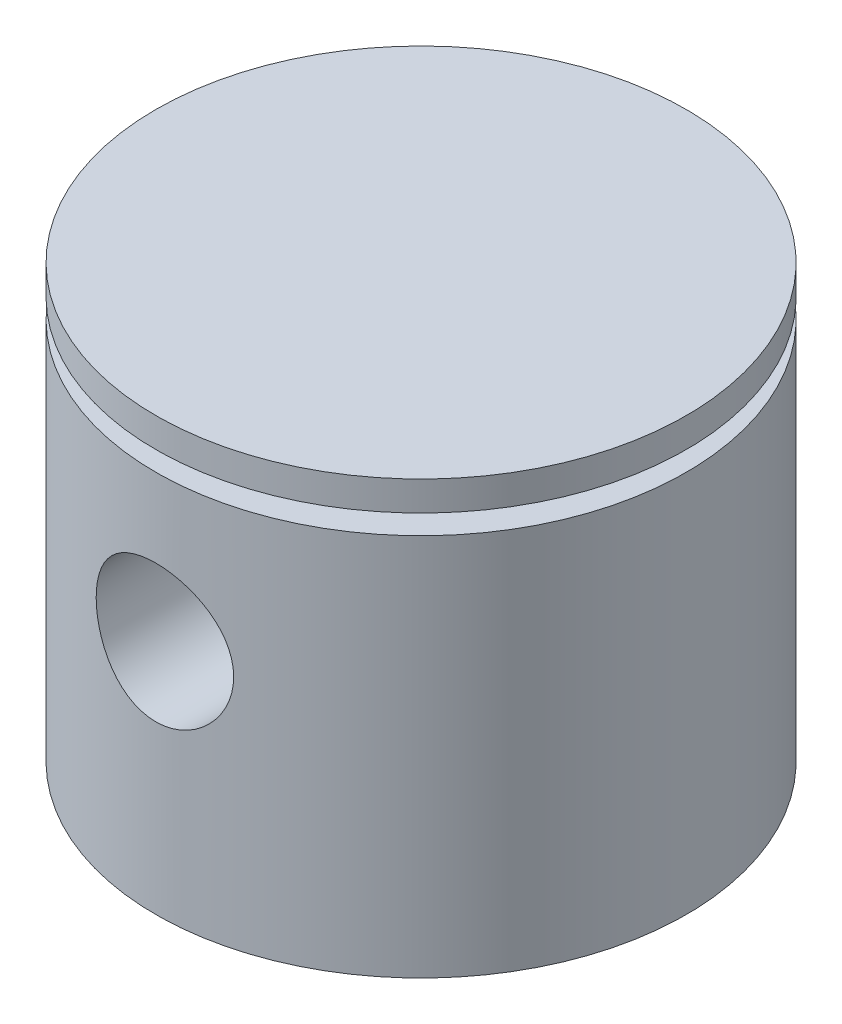
from build123d import *

# Parameters (mm, degrees)
ESQUISSE2_R                  = 3.5
ENL_V_MAT_EXTRU_1_DEPTH      = 14.5
ENL_V_MAT_EXTRU_1_DEPTH_BACK = 14.5


with BuildPart() as part:
    # Esquisse1 → Révolution1 (revolve)
    with BuildSketch(Plane.XY):
        Polygon((0, 0), (0, -3), (-7, -3), (-7, -16), (-12, -16), (-12, -22), (-13.5, -22), (-13.5, -2.5), (-11.5, -2.5), (-11.5, -1.5), (-13.5, -1.5), (-13.5, 0), align=None)
    revolve(axis=Axis((0, 0, 0), (0, -1, 0)))

    # Esquisse2 → Enlèv. mat.-Extru.1 (cut, two sides)
    with BuildSketch(Plane.XY) as enl_v_mat_extru_1_sk:
        with Locations((0, -10)):
            Circle(ESQUISSE2_R)
    extrude(amount=ENL_V_MAT_EXTRU_1_DEPTH, mode=Mode.SUBTRACT)
    extrude(enl_v_mat_extru_1_sk.sketch, amount=-ENL_V_MAT_EXTRU_1_DEPTH_BACK, mode=Mode.SUBTRACT)


solid = part.part
